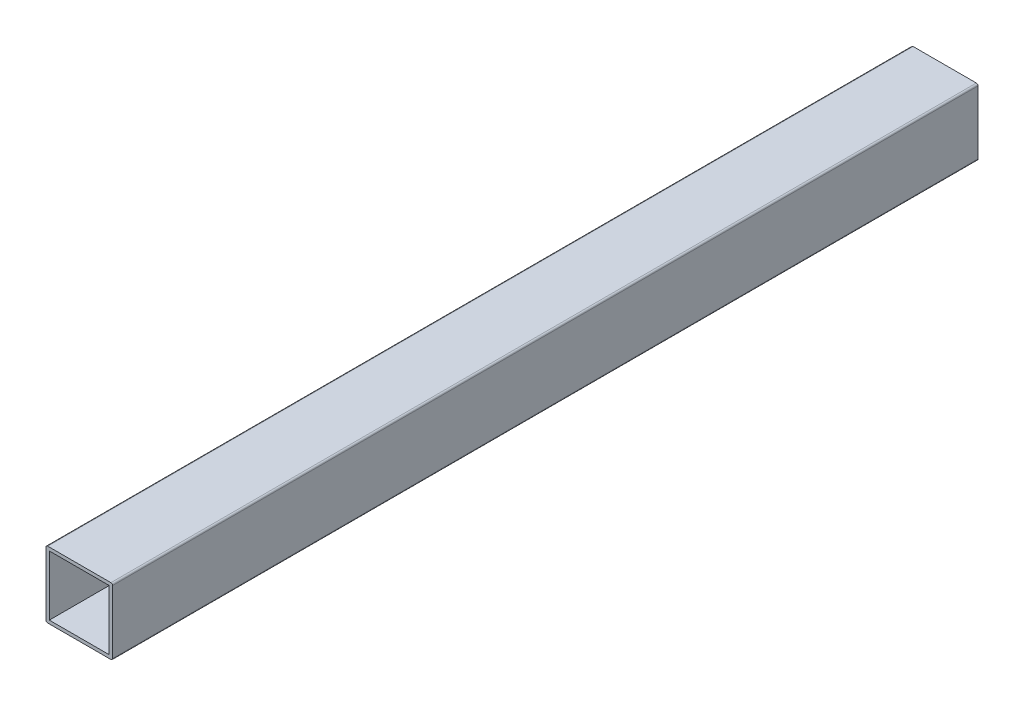
from build123d import *

# Parameters (mm, degrees)
SKETCH1_W           = 18
SKETCH1_H           = 18
EXTRUDE_THIN1_DEPTH = 260
SKETCH2_R           = 3.4
CUT_EXTRUDE1_DEPTH  = 10


with BuildPart() as part:
    # Sketch1 → Extrude-Thin1 (new body)
    with BuildSketch(Plane.XY):
        with BuildLine():
            Line((-10, 9.5), (-10, -9.5))
            ThreePointArc((-10, -9.5), (-9.853553391, -9.853553391), (-9.5, -10))
            Line((-9.5, -10), (9.5, -10))
            ThreePointArc((9.5, -10), (9.853553391, -9.853553391), (10, -9.5))
            Line((10, -9.5), (10, 9.5))
            ThreePointArc((10, 9.5), (9.853553391, 9.853553391), (9.5, 10))
            Line((9.5, 10), (-9.5, 10))
            ThreePointArc((-9.5, 10), (-9.853553391, 9.853553391), (-10, 9.5))
        make_face()
        Rectangle(SKETCH1_W, SKETCH1_H, mode=Mode.SUBTRACT)
    extrude(amount=EXTRUDE_THIN1_DEPTH)

    # Sketch2 → Cut-Extrude1 (cut)
    with BuildSketch(Plane.ZY.offset(10)):
        with Locations((64, 0)):
            Circle(SKETCH2_R)
        with Locations((164, 0)):
            Circle(SKETCH2_R)
        with Locations((196, 0)):
            Circle(SKETCH2_R)
        with Locations((96, 0)):
            Circle(SKETCH2_R)
    extrude(amount=-CUT_EXTRUDE1_DEPTH, mode=Mode.SUBTRACT)


solid = part.part
